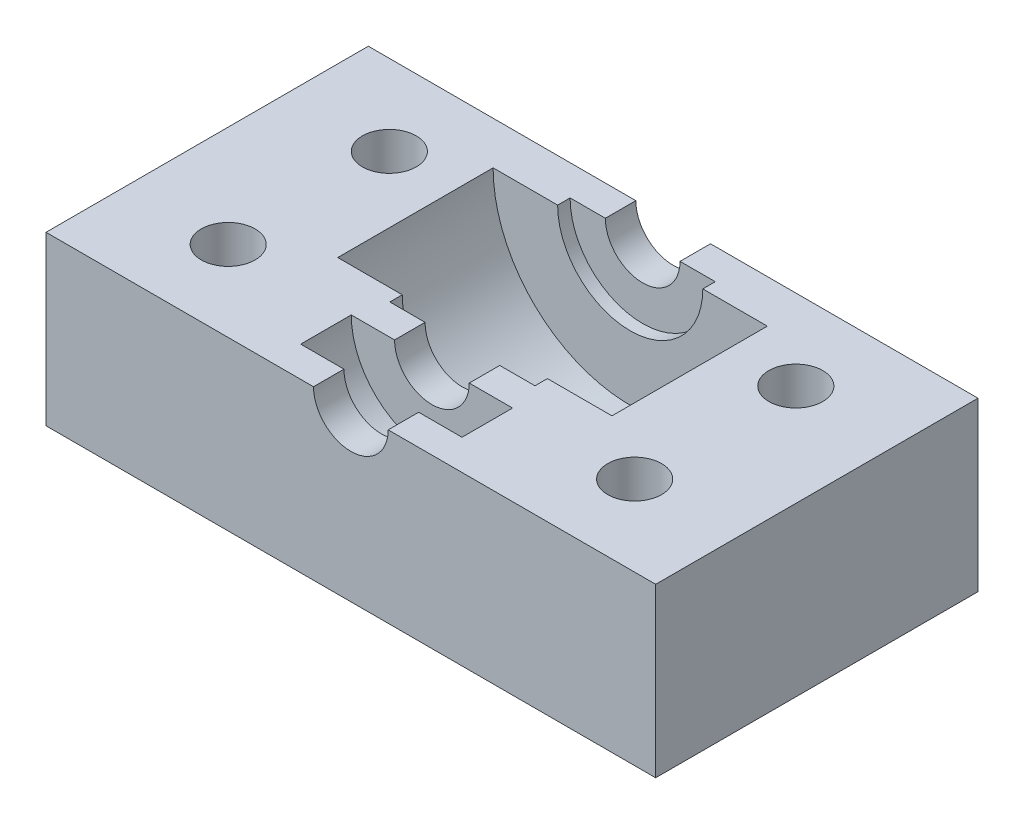
from build123d import *

# Parameters (mm, degrees)
BASE_BOSS_EXTRUDE_DEPTH            = 16.49375
LEAD_SCREW_PILLOW_BLOCK_SKETCH_4_W = 3.675
LEAD_SCREW_PILLOW_BLOCK_SKETCH_4_H = 3
M5_CLEARANCE_HOLE2_D               = 5.3


with BuildPart() as part:
    # Lead Screw Pillow Block Sketch → Base Boss-Extrude (new body)
    with BuildSketch(Plane(origin=(0, 0, 0), x_dir=(1, 0, 0), z_dir=(0, 1, 0))):
        Polygon((30, 15.86015), (0, 15.86015), (0, 12.86015), (0, 11.6346), (0, -3.6562), (0, -4.88175), (0, -7.88175), (0, -12.86015), (0, -15.86015), (30, -15.86015), align=None)
    base_boss_extrude = extrude(amount=-BASE_BOSS_EXTRUDE_DEPTH)

    # Lead Screw Pillow Block Sketch_4 → Pillow Cut-Revolve (revolve, cut)
    with BuildSketch(Plane(origin=(0, 0, 0), x_dir=(1, 0, 0), z_dir=(0, 1, 0))):
        with Locations((-1.8375, 14.36015)):
            Rectangle(LEAD_SCREW_PILLOW_BLOCK_SKETCH_4_W, LEAD_SCREW_PILLOW_BLOCK_SKETCH_4_H)
        Polygon((0, 11.6346), (0, 12.86015), (-3.675, 12.86015), (-7.14375, 12.86015), (-7.14375, 11.6346), align=None)
        Polygon((0, -3.6562), (0, 11.6346), (-7.14375, 11.6346), (-13.49375, 11.6346), (-13.49375, -3.6562), (-7.14375, -3.6562), align=None)
        Polygon((0, -4.88175), (0, -3.6562), (-7.14375, -3.6562), (-7.14375, -4.88175), (-3.675, -4.88175), align=None)
        with Locations((-1.8375, -6.38175)):
            Rectangle(LEAD_SCREW_PILLOW_BLOCK_SKETCH_4_W, LEAD_SCREW_PILLOW_BLOCK_SKETCH_4_H)
        Polygon((-3.675, -12.86015), (0, -12.86015), (0, -7.88175), (-3.675, -7.88175), (-7.9375, -7.88175), (-7.9375, -12.86015), align=None)
        with Locations((-1.8375, -14.36015)):
            Rectangle(LEAD_SCREW_PILLOW_BLOCK_SKETCH_4_W, LEAD_SCREW_PILLOW_BLOCK_SKETCH_4_H)
    pillow_cut_revolve = revolve(axis=Axis((0, 0, -15.86015), (0, 0, 1)), mode=Mode.SUBTRACT)

    # M5 Clearance Hole2 (through all)
    with Locations(Plane(origin=(0, -16.49375, 0), x_dir=(-1, 0, 0), z_dir=(0, -1, 0))):
        with Locations((-20, 7.930075), (-20, -7.930075)):
            m5_clearance_hole2 = Hole(M5_CLEARANCE_HOLE2_D / 2)

    # Mirror1: Base Boss-Extrude, Pillow Cut-Revolve, M5 Clearance Hole2 across plane
    add(base_boss_extrude.mirror(Plane(origin=(0, 0, 0), x_dir=(0, 0, 1), z_dir=(1, 0, 0))))
    add(pillow_cut_revolve.mirror(Plane(origin=(0, 0, 0), x_dir=(0, 0, 1), z_dir=(1, 0, 0))), mode=Mode.SUBTRACT)
    add(m5_clearance_hole2.mirror(Plane(origin=(0, 0, 0), x_dir=(0, 0, 1), z_dir=(1, 0, 0))), mode=Mode.SUBTRACT)


solid = part.part
